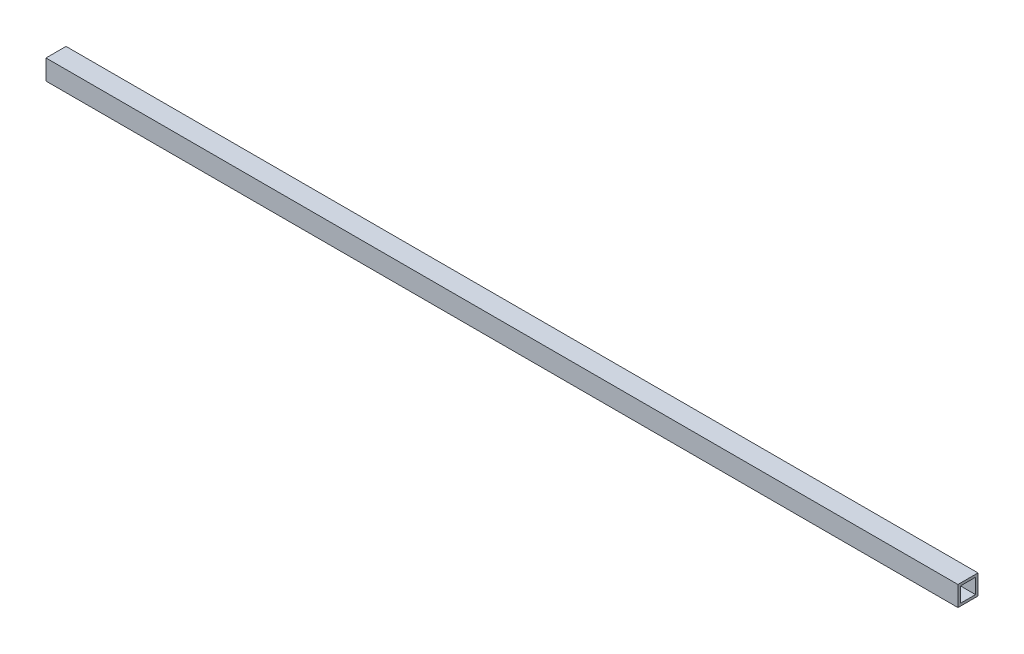
from build123d import *

# Parameters (mm, degrees)
SCHIZZO1_W                   = 40
SCHIZZO1_H                   = 40
SCHIZZO1_W_2                 = 30
SCHIZZO1_H_2                 = 30
ESTRUSIONE_ESTRUSIONE1_DEPTH = 910


with BuildPart() as part:
    # Schizzo1 → Estrusione-Estrusione1 (new body, symmetric)
    with BuildSketch(Plane(origin=(0, 0, 0), x_dir=(0, -1, 0), z_dir=(1, 0, 0))):
        Rectangle(SCHIZZO1_W, SCHIZZO1_H)
        Rectangle(SCHIZZO1_W_2, SCHIZZO1_H_2, mode=Mode.SUBTRACT)
    extrude(amount=ESTRUSIONE_ESTRUSIONE1_DEPTH, both=True)


solid = part.part
